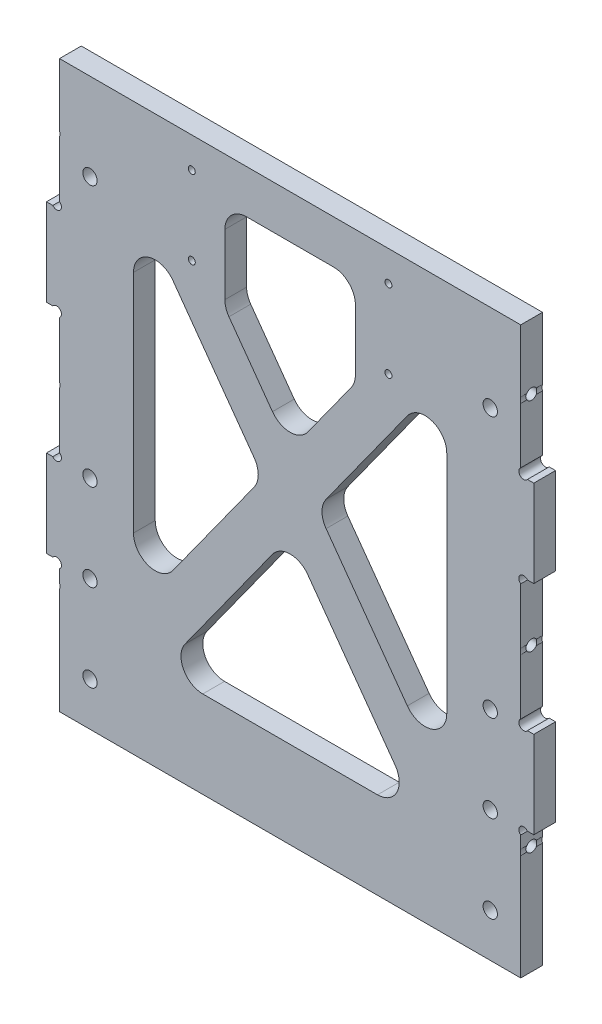
from build123d import *

# Parameters (mm, degrees)
EXTRUDE_1_DEPTH     = 5
SKETCH_2_R          = 1.25
CUT_EXTRUDE_1_DEPTH = 10
SKETCH_3_R          = 1.65
CUT_EXTRUDE_2_DEPTH = 10
SKETCH_5_R          = 0.8
CUT_EXTRUDE_4_DEPTH = 10
CUT_EXTRUDE_3_DEPTH = 10
FILLET_2_R          = 5


with BuildPart() as part:
    # ｽｹｯﾁ1 → ﾎﾞｽ - 押し出し1 (new body)
    with BuildSketch(Plane.XY):
        with BuildLine():
            Line((-53, -40.640312424), (-53, -65))
            Line((-53, -65), (53, -65))
            Line((53, -65), (53, -40.640312424))
            ThreePointArc((53, -40.640312424), (52.9, -40), (53, -39.359687576))
            Line((53, -39.359687576), (53, -36.54))
            ThreePointArc((53, -36.54), (52.882182541, -34.882182541), (54.54, -35))
            Line((54.54, -35), (56, -35))
            Line((56, -35), (56, -15))
            Line((56, -15), (54.54, -15))
            ThreePointArc((54.54, -15), (52.882182541, -15.117817459), (53, -13.46))
            Line((53, -13.46), (53, -0.640312424))
            ThreePointArc((53, -0.640312424), (52.9, 0), (53, 0.640312424))
            Line((53, 0.640312424), (53, 13.46))
            ThreePointArc((53, 13.46), (52.882182541, 15.117817459), (54.54, 15))
            Line((54.54, 15), (56, 15))
            Line((56, 15), (56, 35))
            Line((56, 35), (54.54, 35))
            ThreePointArc((54.54, 35), (52.882182541, 34.882182541), (53, 36.54))
            Line((53, 36.54), (53, 49.359687576))
            ThreePointArc((53, 49.359687576), (52.9, 50), (53, 50.640312424))
            Line((53, 50.640312424), (53, 65))
            Line((53, 65), (-53, 65))
            Line((-53, 65), (-53, 50.640312424))
            ThreePointArc((-53, 50.640312424), (-52.9, 50), (-53, 49.359687576))
            Line((-53, 49.359687576), (-53, 36.54))
            ThreePointArc((-53, 36.54), (-52.882182541, 34.882182541), (-54.54, 35))
            Line((-54.54, 35), (-56, 35))
            Line((-56, 35), (-56, 15))
            Line((-56, 15), (-54.54, 15))
            ThreePointArc((-54.54, 15), (-52.882182541, 15.117817459), (-53, 13.46))
            Line((-53, 13.46), (-53, 0.640312424))
            ThreePointArc((-53, 0.640312424), (-52.9, 0), (-53, -0.640312424))
            Line((-53, -0.640312424), (-53, -13.46))
            ThreePointArc((-53, -13.46), (-52.882182541, -15.117817459), (-54.54, -15))
            Line((-54.54, -15), (-56, -15))
            Line((-56, -15), (-56, -35))
            Line((-56, -35), (-54.54, -35))
            ThreePointArc((-54.54, -35), (-52.882182541, -34.882182541), (-53, -36.54))
            Line((-53, -36.54), (-53, -39.359687576))
            ThreePointArc((-53, -39.359687576), (-52.9, -40), (-53, -40.640312424))
        make_face()
    extrude(amount=EXTRUDE_1_DEPTH)

    # ｽｹｯﾁ2 → ｶｯﾄ - 押し出し1 (cut)
    with BuildSketch(Plane.ZY.offset(53)):
        with Locations((2.5, -40)):
            Circle(SKETCH_2_R)
        with Locations((2.5, 0)):
            Circle(SKETCH_2_R)
        with Locations((2.5, 50)):
            Circle(SKETCH_2_R)
    cut_extrude_1 = extrude(amount=-CUT_EXTRUDE_1_DEPTH, mode=Mode.SUBTRACT)

    # ﾐﾗｰ1: ｶｯﾄ - 押し出し1 across plane
    add(cut_extrude_1.mirror(Plane(origin=(0, 0, 0), x_dir=(0, 0, 1), z_dir=(1, 0, 0))), mode=Mode.SUBTRACT)

    # ｽｹｯﾁ3 → ｶｯﾄ - 押し出し2 (cut)
    with BuildSketch(Plane.XY.offset(5)):
        with Locations((-46, -55)):
            Circle(SKETCH_3_R)
        with Locations((46, -55)):
            Circle(SKETCH_3_R)
        with Locations((46, -35)):
            Circle(SKETCH_3_R)
        with Locations((-46, -35)):
            Circle(SKETCH_3_R)
        with Locations((-46, -15)):
            Circle(SKETCH_3_R)
        with Locations((46, -15)):
            Circle(SKETCH_3_R)
        with Locations((-46, 45)):
            Circle(SKETCH_3_R)
        with Locations((46, 45)):
            Circle(SKETCH_3_R)
    extrude(amount=-CUT_EXTRUDE_2_DEPTH, mode=Mode.SUBTRACT)

    # ｽｹｯﾁ5 → ｶｯﾄ - 押し出し4 (cut)
    with BuildSketch(Plane.XY.offset(5)):
        with Locations((-22.6, 40)):
            Circle(SKETCH_5_R)
        with Locations((22.6, 40)):
            Circle(SKETCH_5_R)
        with Locations((22.6, 58)):
            Circle(SKETCH_5_R)
        with Locations((-22.6, 58)):
            Circle(SKETCH_5_R)
    extrude(amount=-CUT_EXTRUDE_4_DEPTH, mode=Mode.SUBTRACT)

    # ｽｹｯﾁ4 → ｶｯﾄ - 押し出し3 (cut)
    with BuildSketch(Plane.XY.offset(5)):
        Polygon((-36, -36.442821222), (-6.16116872, 5), (-36, 46.442821222), align=None)
        Polygon((36, 46.442821222), (6.16116872, 5), (36, -36.442821222), align=None)
        Polygon((29.83883128, -45), (0, -3.557178778), (-29.83883128, -45), align=None)
        Polygon((15, 55), (-15, 55), (-15, 34.390512112), (0, 13.557178778), (15, 34.390512112), align=None)
    extrude(amount=-CUT_EXTRUDE_3_DEPTH, mode=Mode.SUBTRACT)

    # ﾌｨﾚｯﾄ2
    fillet_2_edges = [part.edges().sort_by_distance(p)[0] for p in [
        (-29.83883128, -45, 2.5),
        (0, -3.557178778, 2.5),
        (29.83883128, -45, 2.5),
        (6.16116872, 5, 2.5),
        (36, 46.442821222, 2.5),
        (36, -36.442821222, 2.5),
        (15, 55, 2.5),
        (15, 34.390512112, 2.5),
        (0, 13.557178778, 2.5),
        (-15, 34.390512112, 2.5),
        (-15, 55, 2.5),
        (-36, -36.442821222, 2.5),
        (-36, 46.442821222, 2.5),
        (-6.16116872, 5, 2.5),
    ]]
    fillet(fillet_2_edges, radius=FILLET_2_R)


solid = part.part
